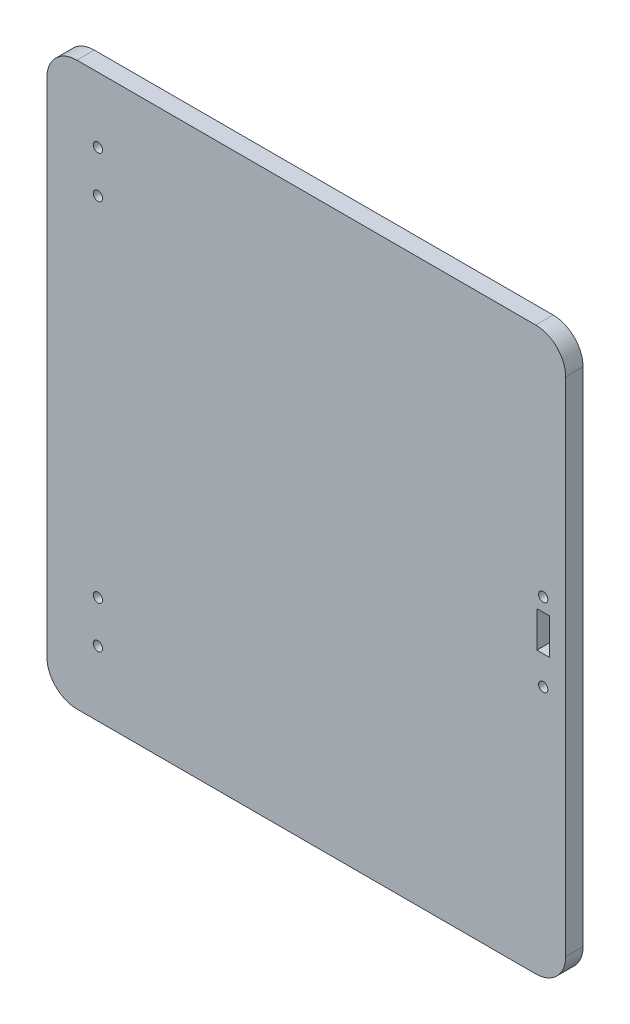
from build123d import *

# Parameters (mm, degrees)
BOSS_EXTRUDE1_DEPTH = 5.8
SKETCH3_W           = 4.2
SKETCH3_H           = 12
CUT_EXTRUDE1_DEPTH  = 6.35
SKETCH4_R           = 1.55
CUT_EXTRUDE2_DEPTH  = 6.8
SKETCH5_R           = 1.55
CUT_EXTRUDE3_DEPTH  = 6.8


with BuildPart() as part:
    # Sketch2 → Boss-Extrude1 (new body)
    with BuildSketch(Plane.XY):
        with BuildLine():
            Line((76.5, 93.7), (-76.5, 93.7))
            ThreePointArc((-76.5, 93.7), (-83.571067812, 90.771067812), (-86.5, 83.7))
            Line((-86.5, 83.7), (-86.5, -83.7))
            ThreePointArc((-86.5, -83.7), (-83.571067812, -90.771067812), (-76.5, -93.7))
            Line((-76.5, -93.7), (76.5, -93.7))
            ThreePointArc((76.5, -93.7), (83.571067812, -90.771067812), (86.5, -83.7))
            Line((86.5, -83.7), (86.5, 83.7))
            ThreePointArc((86.5, 83.7), (83.571067812, 90.771067812), (76.5, 93.7))
        make_face()
    extrude(amount=BOSS_EXTRUDE1_DEPTH)

    # Sketch3 → Cut-Extrude1 (cut)
    with BuildSketch(Plane.XY.offset(5.8)):
        with Locations((79, 6)):
            Rectangle(SKETCH3_W, SKETCH3_H)
    extrude(amount=-CUT_EXTRUDE1_DEPTH, mode=Mode.SUBTRACT)

    # Sketch4 → Cut-Extrude2 (cut, through all)
    with BuildSketch(Plane.XY.offset(5.8)):
        with Locations((-69.5, 72)):
            Circle(SKETCH4_R)
        with Locations((-69.5, 58)):
            Circle(SKETCH4_R)
        with Locations((-69.5, -58)):
            Circle(SKETCH4_R)
        with Locations((-69.5, -72)):
            Circle(SKETCH4_R)
    extrude(amount=-CUT_EXTRUDE2_DEPTH, mode=Mode.SUBTRACT)

    # Sketch5 → Cut-Extrude3 (cut, through all)
    with BuildSketch(Plane.XY.offset(5.8)):
        with Locations((79, 16.45)):
            Circle(SKETCH5_R)
        with Locations((79, -9.55)):
            Circle(SKETCH5_R)
    extrude(amount=-CUT_EXTRUDE3_DEPTH, mode=Mode.SUBTRACT)


solid = part.part
